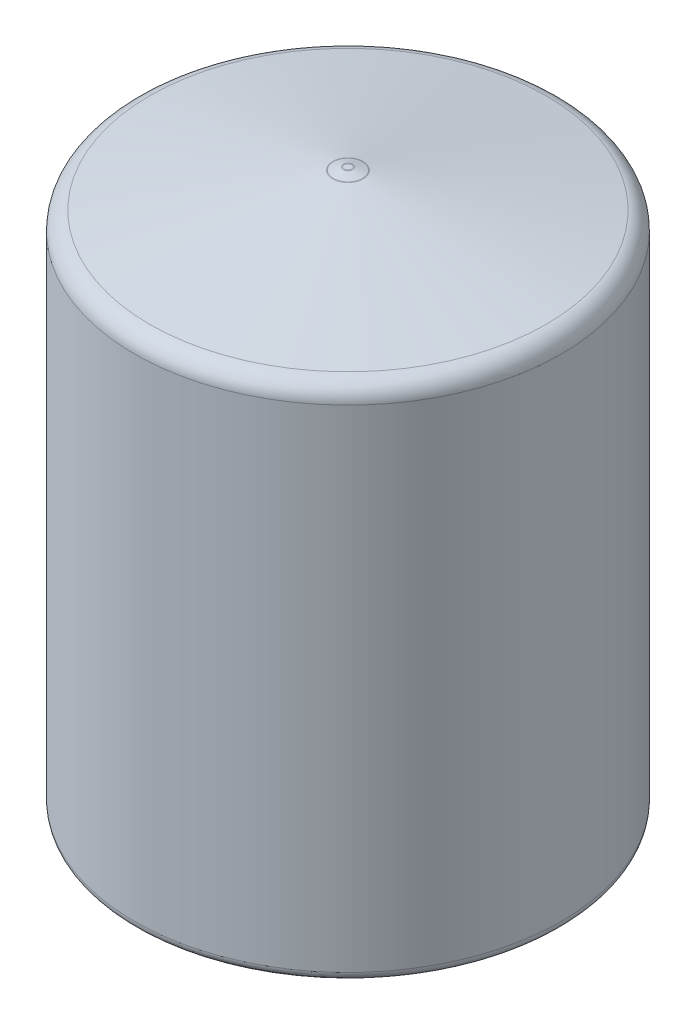
from build123d import *

# Parameters (mm, degrees)
FILLET1_R = 0.5


with BuildPart() as part:
    # Sketch1 → Revolve1 (revolve)
    with BuildSketch(Plane.XY):
        with BuildLine():
            Line((10, 0), (10, 26.585564127))
            Line((10, 26.585564127), (1.265397394, 28.234602606))
            Line((1.265397394, 28.234602606), (0, 29.5))
            Line((0, 29.5), (0, 30))
            Line((0, 30), (0.2, 30))
            ThreePointArc((0.2, 30), (0.225652916, 29.998347997), (0.250882045, 29.993419279))
            Line((0.250882045, 29.993419279), (0.8, 29.848964991))
            Line((0.8, 29.848964991), (10.685516518, 27.982641146))
            ThreePointArc((10.685516518, 27.982641146), (11.269907955, 27.638154951), (11.5, 27))
            Line((11.5, 27), (11.5, 0))
            Line((11.5, 0), (10, 0))
        make_face()
    revolve(axis=Axis((0, 9.5, 0), (0, -1, 0)))

    # Fillet1
    fillet1_edges = [part.edges().sort_by_distance(p)[0] for p in [
        (-0.8, 29.848964991, 0),
        (-11.5, 0, 0),
        (-10, 0, 0),
    ]]
    fillet(fillet1_edges, radius=FILLET1_R)


solid = part.part
